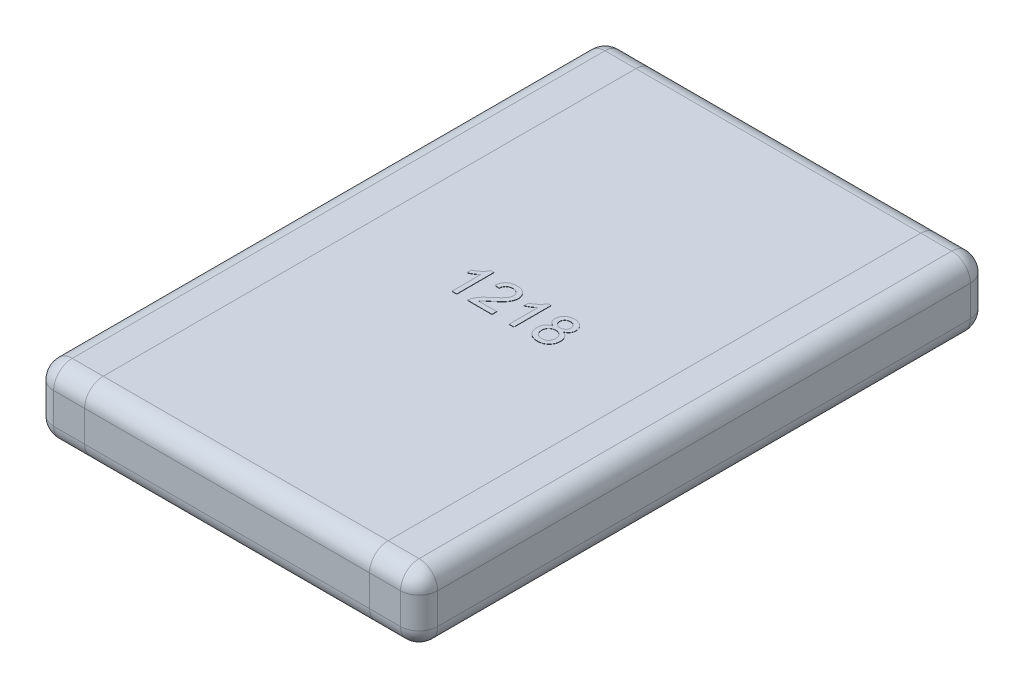
from build123d import *

# Parameters (mm, degrees)
SKETCH1_W      = 3.1
SKETCH1_H      = 4.6
EXTRUDE1_DEPTH = 0.55
FILLET1_R      = 0.15
EXTRUDE2_DEPTH = 0.002


with BuildPart() as part:
    # Sketch1 → Extrude1 (new body)
    with BuildSketch(Plane(origin=(0, 0, 0), x_dir=(1, 0, 0), z_dir=(0, 1, 0))):
        Rectangle(SKETCH1_W, SKETCH1_H)
    extrude(amount=EXTRUDE1_DEPTH)

    # Fillet1
    fillet1_edges = [part.edges().sort_by_distance(p)[0] for p in [
        (1.55, 0.55, 0),
        (0, 0.55, -2.3),
        (-1.55, 0.55, 0),
        (0, 0, -2.3),
        (1.55, 0, 0),
        (0, 0, 2.3),
        (-1.55, 0, 0),
        (0, 0.55, 2.3),
        (-1.55, 0.275, -2.3),
        (1.55, 0.275, -2.3),
        (1.55, 0.275, 2.3),
        (-1.55, 0.275, 2.3),
    ]]
    fillet(fillet1_edges, radius=FILLET1_R)

    # Sketch3 → Extrude2 (add)
    with BuildSketch(Plane(origin=(0, 0.55, 0), x_dir=(1, 0, 0), z_dir=(0, 1, 0))):
        with BuildLine():
            Line((-0.296153846, -0.15), (-0.334615385, -0.15))
            Line((-0.334615385, -0.15), (-0.334615385, 0.083774038))
            add(Edge.make_bspline(
                [(-0.334615385, 0.083774038), (-0.336830003, 0.081638311), (-0.341432846, 0.077199436), (-0.349213465, 0.070917319), (-0.35789763, 0.064550127), (-0.367372572, 0.05842736), (-0.377030672, 0.052663436), (-0.386363982, 0.047479672), (-0.39521668, 0.04309295), (-0.401047999, 0.040694273), (-0.403846154, 0.039543269)],
                knots=[0, 0, 0, 0, 9.226e-06, 1.9175e-05, 2.9969e-05, 4.1521e-05, 5.3002e-05, 6.3707e-05, 7.3544e-05, 8.2619e-05, 8.2619e-05, 8.2619e-05, 8.2619e-05], degree=3))
            Line((-0.403846154, 0.039543269), (-0.403846154, 0.075))
            add(Edge.make_bspline(
                [(-0.403846154, 0.075), (-0.399040034, 0.077475162), (-0.389567455, 0.082353558), (-0.37618475, 0.09077922), (-0.363690555, 0.099912985), (-0.352291699, 0.10975283), (-0.342073351, 0.119810917), (-0.333462201, 0.129959923), (-0.326256938, 0.139827828), (-0.322641922, 0.146709597), (-0.320913462, 0.15)],
                knots=[0, 0, 0, 0, 1.6212e-05, 3.1953e-05, 4.7386e-05, 6.26e-05, 7.7091e-05, 9.0349e-05, 0.000102505, 0.000113642, 0.000113642, 0.000113642, 0.000113642], degree=3))
            Line((-0.320913462, 0.15), (-0.296153846, 0.15))
            Line((-0.296153846, 0.15), (-0.296153846, -0.15))
        make_face()
        with BuildLine():
            Line((-0.011538462, -0.111538462), (-0.011538462, -0.15))
            Line((-0.011538462, -0.15), (-0.207692308, -0.15))
            add(Edge.make_bspline(
                [(-0.207692308, -0.15), (-0.207696323, -0.147714123), (-0.207704342, -0.14315003), (-0.206932024, -0.136400026), (-0.205722419, -0.129739566), (-0.204354719, -0.125468478), (-0.203665865, -0.123317308)],
                knots=[0, 0, 0, 0, 6.852e-06, 1.3681e-05, 2.0352e-05, 2.7121e-05, 2.7121e-05, 2.7121e-05, 2.7121e-05], degree=3))
            add(Edge.make_bspline(
                [(-0.203665865, -0.123317308), (-0.202393093, -0.119802551), (-0.199801518, -0.112645929), (-0.19455096, -0.102319922), (-0.188375063, -0.092056365), (-0.182361958, -0.08370038), (-0.176855252, -0.077024532), (-0.172237162, -0.071801454), (-0.167119471, -0.066455018), (-0.161506278, -0.060986201), (-0.155451607, -0.055359583), (-0.148947197, -0.049556401), (-0.141916239, -0.043684801), (-0.137007895, -0.039792861), (-0.134495192, -0.037800481)],
                knots=[0, 0, 0, 0, 1.1205e-05, 2.2816e-05, 3.4678e-05, 4.712e-05, 5.3653e-05, 6.0635e-05, 6.8031e-05, 7.5851e-05, 8.4142e-05, 9.2826e-05, 0.000101998, 0.000111618, 0.000111618, 0.000111618, 0.000111618], degree=3))
            add(Edge.make_bspline(
                [(-0.134495192, -0.037800481), (-0.130635061, -0.034551471), (-0.123202132, -0.028295295), (-0.112705672, -0.019011711), (-0.103118865, -0.010391377), (-0.094594368, -0.002283205), (-0.087062462, 0.005234162), (-0.080505461, 0.012143692), (-0.074866946, 0.018423822), (-0.070215752, 0.024301865), (-0.066291398, 0.029852373), (-0.062965854, 0.035266551), (-0.060194454, 0.040638972), (-0.057886249, 0.045952637), (-0.056060655, 0.05123027), (-0.054816253, 0.056487246), (-0.053972343, 0.061671403), (-0.053887909, 0.065120999), (-0.053846154, 0.066826923)],
                knots=[0, 0, 0, 0, 1.5136e-05, 2.9145e-05, 4.2036e-05, 5.3811e-05, 6.4435e-05, 7.3957e-05, 8.2386e-05, 8.9745e-05, 9.643e-05, 0.000102769, 0.00010879, 0.00011455, 0.000120137, 0.000125516, 0.000130743, 0.000135857, 0.000135857, 0.000135857, 0.000135857], degree=3))
            add(Edge.make_bspline(
                [(-0.053846154, 0.066826923), (-0.053887914, 0.068512943), (-0.053969845, 0.071820821), (-0.054747201, 0.076661881), (-0.055829343, 0.081323937), (-0.057578837, 0.085723063), (-0.059661262, 0.089989532), (-0.062332474, 0.093988532), (-0.065422517, 0.097819726), (-0.068960356, 0.101382104), (-0.072824504, 0.104724183), (-0.077142138, 0.107502263), (-0.081629679, 0.110003363), (-0.086441941, 0.11201439), (-0.091571106, 0.113491124), (-0.096979835, 0.114562852), (-0.10266727, 0.115242385), (-0.106548545, 0.115336486), (-0.108533654, 0.115384615)],
                knots=[0, 0, 0, 0, 5.054e-06, 9.915e-06, 1.4681e-05, 1.938e-05, 2.4083e-05, 2.89e-05, 3.3772e-05, 3.8829e-05, 4.3946e-05, 4.9063e-05, 5.4199e-05, 5.9345e-05, 6.4669e-05, 7.0185e-05, 7.5872e-05, 8.1827e-05, 8.1827e-05, 8.1827e-05, 8.1827e-05], degree=3))
            add(Edge.make_bspline(
                [(-0.108533654, 0.115384615), (-0.110618956, 0.115336725), (-0.114700045, 0.115242999), (-0.120665504, 0.114560756), (-0.126328674, 0.113518381), (-0.131676037, 0.111924678), (-0.136701084, 0.109917004), (-0.141383351, 0.107389877), (-0.145797819, 0.104537208), (-0.149805459, 0.101159863), (-0.153429516, 0.097415076), (-0.156646835, 0.093338135), (-0.159282944, 0.088850365), (-0.161459952, 0.084050442), (-0.163210448, 0.078923275), (-0.164481249, 0.07342967), (-0.165174098, 0.067585487), (-0.165313425, 0.063583392), (-0.165384615, 0.061538462)],
                knots=[0, 0, 0, 0, 6.255e-06, 1.2241e-05, 1.7992e-05, 2.3507e-05, 2.8953e-05, 3.4195e-05, 3.9446e-05, 4.4693e-05, 4.9878e-05, 5.506e-05, 6.0233e-05, 6.5451e-05, 7.0848e-05, 7.6461e-05, 8.2334e-05, 8.8471e-05, 8.8471e-05, 8.8471e-05, 8.8471e-05], degree=3))
            Line((-0.165384615, 0.061538462), (-0.203846154, 0.065384615))
            add(Edge.make_bspline(
                [(-0.203846154, 0.065384615), (-0.203452638, 0.068736632), (-0.202687086, 0.075257693), (-0.200780201, 0.084702351), (-0.198103106, 0.09348859), (-0.194899737, 0.101738909), (-0.190884012, 0.109312863), (-0.18634458, 0.11636711), (-0.18099053, 0.122677919), (-0.175075725, 0.128444216), (-0.168535362, 0.133525841), (-0.161430878, 0.137965346), (-0.153765522, 0.141678718), (-0.145581988, 0.144753235), (-0.136861488, 0.147085948), (-0.12761636, 0.148758724), (-0.117831734, 0.149789842), (-0.111120341, 0.149928948), (-0.107692308, 0.15)],
                knots=[0, 0, 0, 0, 1.0123e-05, 1.9693e-05, 2.8857e-05, 3.7651e-05, 4.6199e-05, 5.4533e-05, 6.2766e-05, 7.0968e-05, 7.9275e-05, 8.7563e-05, 9.6056e-05, 0.000104785, 0.00011375, 0.000123098, 0.000132946, 0.000143229, 0.000143229, 0.000143229, 0.000143229], degree=3))
            add(Edge.make_bspline(
                [(-0.107692308, 0.15), (-0.104223243, 0.149940596), (-0.097465484, 0.149824877), (-0.087618344, 0.14864084), (-0.078327294, 0.146796713), (-0.069558275, 0.144226564), (-0.061363096, 0.140856333), (-0.053735451, 0.136738671), (-0.046640172, 0.131913745), (-0.040195807, 0.126323636), (-0.034384754, 0.120221095), (-0.029292223, 0.113708369), (-0.025034622, 0.106813279), (-0.021409539, 0.09962981), (-0.018720681, 0.092006182), (-0.016829827, 0.084046037), (-0.015544936, 0.075742575), (-0.015438766, 0.070077103), (-0.015384615, 0.0671875)],
                knots=[0, 0, 0, 0, 1.0403e-05, 2.0265e-05, 2.9705e-05, 3.8794e-05, 4.7633e-05, 5.6238e-05, 6.4755e-05, 7.3321e-05, 8.178e-05, 9.0002e-05, 9.8073e-05, 0.000106055, 0.000114096, 0.000122258, 0.000130579, 0.00013924, 0.00013924, 0.00013924, 0.00013924], degree=3))
            add(Edge.make_bspline(
                [(-0.015384615, 0.0671875), (-0.015467303, 0.06421876), (-0.01563286, 0.058274728), (-0.016925056, 0.049390154), (-0.019136019, 0.040601997), (-0.022067165, 0.0318033), (-0.026071721, 0.022959142), (-0.031130797, 0.013947517), (-0.037407134, 0.004735138), (-0.04344321, -0.003096409), (-0.049061817, -0.009661219), (-0.054042181, -0.015064442), (-0.059804175, -0.020805005), (-0.066131643, -0.027081717), (-0.073282651, -0.033671804), (-0.081051734, -0.040772611), (-0.089608959, -0.048197271), (-0.095549342, -0.053269443), (-0.098617788, -0.055889423)],
                knots=[0, 0, 0, 0, 8.904e-06, 1.7828e-05, 2.6865e-05, 3.6063e-05, 4.5612e-05, 5.5944e-05, 6.7028e-05, 7.9024e-05, 8.5588e-05, 9.2946e-05, 0.000101063, 0.000109987, 0.000119681, 0.000130232, 0.000141562, 0.000153666, 0.000153666, 0.000153666, 0.000153666], degree=3))
            add(Edge.make_bspline(
                [(-0.098617788, -0.055889423), (-0.101245449, -0.058028619), (-0.106255994, -0.062107737), (-0.113384465, -0.068021343), (-0.119769407, -0.07344396), (-0.12556013, -0.078198712), (-0.130545741, -0.08251558), (-0.13490185, -0.086205504), (-0.138470198, -0.089454013), (-0.14390416, -0.094388563), (-0.150786737, -0.101422266), (-0.155858114, -0.108256719), (-0.158293269, -0.111538462)],
                knots=[0, 0, 0, 0, 1.0165e-05, 1.9383e-05, 2.7786e-05, 3.5295e-05, 4.1859e-05, 4.7569e-05, 5.242e-05, 5.6334e-05, 6.9594e-05, 8.1844e-05, 8.1844e-05, 8.1844e-05, 8.1844e-05], degree=3))
            Line((-0.158293269, -0.111538462), (-0.011538462, -0.111538462))
        make_face()
        with BuildLine():
            Line((0.165384615, -0.15), (0.126923077, -0.15))
            Line((0.126923077, -0.15), (0.126923077, 0.083774038))
            add(Edge.make_bspline(
                [(0.126923077, 0.083774038), (0.124708458, 0.081638311), (0.120105616, 0.077199436), (0.112324997, 0.070917319), (0.103640832, 0.064550127), (0.09416589, 0.05842736), (0.08450779, 0.052663436), (0.075174479, 0.047479672), (0.066321782, 0.04309295), (0.060490463, 0.040694273), (0.057692308, 0.039543269)],
                knots=[0, 0, 0, 0, 9.226e-06, 1.9175e-05, 2.9969e-05, 4.1521e-05, 5.3002e-05, 6.3707e-05, 7.3544e-05, 8.2619e-05, 8.2619e-05, 8.2619e-05, 8.2619e-05], degree=3))
            Line((0.057692308, 0.039543269), (0.057692308, 0.075))
            add(Edge.make_bspline(
                [(0.057692308, 0.075), (0.062498428, 0.077475162), (0.071971006, 0.082353558), (0.085353711, 0.09077922), (0.097847906, 0.099912985), (0.109246762, 0.10975283), (0.11946511, 0.119810917), (0.128076261, 0.129959923), (0.135281523, 0.139827828), (0.13889654, 0.146709597), (0.140625, 0.15)],
                knots=[0, 0, 0, 0, 1.6212e-05, 3.1953e-05, 4.7386e-05, 6.26e-05, 7.7091e-05, 9.0349e-05, 0.000102505, 0.000113642, 0.000113642, 0.000113642, 0.000113642], degree=3))
            Line((0.140625, 0.15), (0.165384615, 0.15))
            Line((0.165384615, 0.15), (0.165384615, -0.15))
        make_face()
        with BuildLine():
            add(Edge.make_bspline(
                [(0.318509615, 0.014543269), (0.314860295, 0.015970904), (0.307863336, 0.018708154), (0.298426244, 0.024186161), (0.290439253, 0.030487887), (0.284000435, 0.037765293), (0.279092884, 0.045867936), (0.275559254, 0.054692508), (0.273489545, 0.06428817), (0.273217147, 0.070923324), (0.273076923, 0.074338942)],
                knots=[0, 0, 0, 0, 1.1742e-05, 2.2513e-05, 3.2603e-05, 4.214e-05, 5.1498e-05, 6.0884e-05, 7.0537e-05, 8.0779e-05, 8.0779e-05, 8.0779e-05, 8.0779e-05], degree=3))
            add(Edge.make_bspline(
                [(0.273076923, 0.074338942), (0.27314292, 0.07696711), (0.273272474, 0.082126286), (0.274391848, 0.089696504), (0.276184688, 0.096950666), (0.278729147, 0.103868299), (0.281916936, 0.11050634), (0.28593939, 0.11674318), (0.29056295, 0.122755082), (0.295979231, 0.128299027), (0.301947879, 0.133376745), (0.308412856, 0.137895415), (0.315423633, 0.141590589), (0.322863319, 0.144680065), (0.330768701, 0.147098798), (0.339167624, 0.148746091), (0.348030483, 0.149793891), (0.354103523, 0.149930227), (0.357211538, 0.15)],
                knots=[0, 0, 0, 0, 7.881e-06, 1.547e-05, 2.2904e-05, 3.0261e-05, 3.7545e-05, 4.4948e-05, 5.2485e-05, 6.0262e-05, 6.8149e-05, 7.5968e-05, 8.3872e-05, 9.1874e-05, 0.000100106, 0.000108627, 0.00011752, 0.000126842, 0.000126842, 0.000126842, 0.000126842], degree=3))
            add(Edge.make_bspline(
                [(0.357211538, 0.15), (0.360339358, 0.149929518), (0.366431998, 0.149792228), (0.375341942, 0.148758507), (0.383793869, 0.147025925), (0.391782801, 0.144567827), (0.399321334, 0.141425001), (0.406359932, 0.137562056), (0.412971053, 0.133042703), (0.418985719, 0.127813048), (0.424458348, 0.122135343), (0.429199864, 0.1160526), (0.433266512, 0.109706754), (0.436626985, 0.103059254), (0.439113075, 0.096034402), (0.441008035, 0.088764549), (0.442107199, 0.081163316), (0.442240027, 0.076005089), (0.442307692, 0.073377404)],
                knots=[0, 0, 0, 0, 9.382e-06, 1.8275e-05, 2.6867e-05, 3.5231e-05, 4.3312e-05, 5.1326e-05, 5.9277e-05, 6.7288e-05, 7.5194e-05, 8.29e-05, 9.0385e-05, 9.7776e-05, 0.00010519, 0.000112697, 0.000120286, 0.000128167, 0.000128167, 0.000128167, 0.000128167], degree=3))
            add(Edge.make_bspline(
                [(0.442307692, 0.073377404), (0.442197773, 0.070079507), (0.441982241, 0.063612951), (0.439785876, 0.054291357), (0.436362653, 0.045589182), (0.431415063, 0.037672273), (0.425149124, 0.030458869), (0.417373593, 0.024188177), (0.408206557, 0.018718731), (0.401386261, 0.015972556), (0.397836538, 0.014543269)],
                knots=[0, 0, 0, 0, 9.878e-06, 1.9369e-05, 2.8564e-05, 3.782e-05, 4.7233e-05, 5.7098e-05, 6.7662e-05, 7.9128e-05, 7.9128e-05, 7.9128e-05, 7.9128e-05], degree=3))
            add(Edge.make_bspline(
                [(0.397836538, 0.014543269), (0.400076183, 0.013783016), (0.404464914, 0.01229325), (0.41066927, 0.009396685), (0.416510485, 0.006273501), (0.422021497, 0.002892652), (0.426998883, -0.000997287), (0.431608702, -0.00516632), (0.435831572, -0.009673198), (0.439609814, -0.014556251), (0.442983014, -0.019712993), (0.445870741, -0.025155995), (0.448323232, -0.030807785), (0.450419215, -0.036694571), (0.451950165, -0.042857817), (0.453021351, -0.049269202), (0.453700988, -0.055894934), (0.453797262, -0.060394987), (0.453846154, -0.062680288)],
                knots=[0, 0, 0, 0, 7.091e-06, 1.3894e-05, 2.0509e-05, 2.6962e-05, 3.326e-05, 3.9429e-05, 4.5594e-05, 5.1761e-05, 5.7929e-05, 6.4058e-05, 7.0221e-05, 7.6399e-05, 8.2783e-05, 8.9244e-05, 9.5888e-05, 0.000102743, 0.000102743, 0.000102743, 0.000102743], degree=3))
            add(Edge.make_bspline(
                [(0.453846154, -0.062680288), (0.45376972, -0.065830053), (0.453619139, -0.07203533), (0.452296087, -0.081143948), (0.450294251, -0.089894018), (0.447375342, -0.098248578), (0.443647171, -0.106213532), (0.439035378, -0.113777315), (0.433585276, -0.120932146), (0.427457634, -0.127700265), (0.420606933, -0.133818351), (0.413195743, -0.139209736), (0.405196258, -0.143725707), (0.396705537, -0.147464915), (0.387682925, -0.150362788), (0.378140019, -0.152391913), (0.368079995, -0.153600168), (0.361201262, -0.15376306), (0.357692308, -0.153846154)],
                knots=[0, 0, 0, 0, 9.444e-06, 1.8606e-05, 2.7557e-05, 3.6337e-05, 4.5101e-05, 5.3893e-05, 6.2859e-05, 7.2048e-05, 8.1241e-05, 9.0365e-05, 9.9489e-05, 0.000108745, 0.000118153, 0.000127865, 0.000137973, 0.000148498, 0.000148498, 0.000148498, 0.000148498], degree=3))
            add(Edge.make_bspline(
                [(0.357692308, -0.153846154), (0.354183704, -0.153761269), (0.347305659, -0.153594866), (0.337236444, -0.152411313), (0.327707192, -0.150290202), (0.318696311, -0.147389384), (0.310154921, -0.143751415), (0.30220916, -0.139133687), (0.294749561, -0.133749133), (0.287894096, -0.127593205), (0.281715554, -0.120825808), (0.276337297, -0.113565311), (0.271752882, -0.105923451), (0.267980008, -0.097857148), (0.265104217, -0.089366329), (0.263085953, -0.080482873), (0.261760507, -0.071213566), (0.26161352, -0.064888503), (0.261538462, -0.061658654)],
                knots=[0, 0, 0, 0, 1.0525e-05, 2.0633e-05, 3.0358e-05, 3.9766e-05, 4.8998e-05, 5.8152e-05, 6.7276e-05, 7.6554e-05, 8.5742e-05, 9.4721e-05, 0.000103615, 0.000112434, 0.000121385, 0.000130452, 0.000139733, 0.000149418, 0.000149418, 0.000149418, 0.000149418], degree=3))
            add(Edge.make_bspline(
                [(0.261538462, -0.061658654), (0.261590633, -0.05925379), (0.261693001, -0.054535032), (0.262318335, -0.047613898), (0.263564614, -0.04101733), (0.265169901, -0.034706454), (0.267208113, -0.028665483), (0.269722636, -0.022941855), (0.2727734, -0.017549405), (0.276239267, -0.012453043), (0.280163974, -0.007688549), (0.284483909, -0.003297645), (0.289214766, 0.000669723), (0.294250232, 0.004329433), (0.299801377, 0.007422605), (0.305661755, 0.010261167), (0.311932122, 0.012681934), (0.31629516, 0.01391661), (0.318509615, 0.014543269)],
                knots=[0, 0, 0, 0, 7.216e-06, 1.4158e-05, 2.0818e-05, 2.7333e-05, 3.3681e-05, 3.9923e-05, 4.6058e-05, 5.2242e-05, 5.839e-05, 6.4552e-05, 7.0692e-05, 7.6896e-05, 8.3194e-05, 8.9726e-05, 9.6422e-05, 0.000103324, 0.000103324, 0.000103324, 0.000103324], degree=3))
        make_face()
        with BuildLine():
            add(Edge.make_bspline(
                [(0.311538462, 0.074158654), (0.311652615, 0.071096846), (0.31187321, 0.065180074), (0.314272205, 0.056775734), (0.318023536, 0.049226279), (0.322421313, 0.043751589), (0.326637678, 0.0400214), (0.330156814, 0.037530885), (0.33400255, 0.035416488), (0.338202746, 0.033773046), (0.342655672, 0.032317058), (0.347514904, 0.031503267), (0.352666229, 0.030841703), (0.35622746, 0.03079379), (0.358052885, 0.030769231)],
                knots=[0, 0, 0, 0, 9.163e-06, 1.7707e-05, 2.5985e-05, 3.4319e-05, 3.8576e-05, 4.2845e-05, 4.7228e-05, 5.1704e-05, 5.6361e-05, 6.1252e-05, 6.6455e-05, 7.1927e-05, 7.1927e-05, 7.1927e-05, 7.1927e-05], degree=3))
            add(Edge.make_bspline(
                [(0.358052885, 0.030769231), (0.359838014, 0.030794697), (0.36331892, 0.030844356), (0.368354225, 0.031492433), (0.37311257, 0.032358), (0.377523642, 0.033669634), (0.381638366, 0.035375141), (0.385389817, 0.037477611), (0.388890258, 0.039893951), (0.392982761, 0.043652639), (0.397374469, 0.048935583), (0.401138372, 0.056147793), (0.403483876, 0.064038379), (0.403723275, 0.069534632), (0.403846154, 0.072355769)],
                knots=[0, 0, 0, 0, 5.352e-06, 1.0435e-05, 1.5209e-05, 1.9848e-05, 2.4212e-05, 2.8543e-05, 3.2728e-05, 3.694e-05, 4.5181e-05, 5.3192e-05, 6.1199e-05, 6.9644e-05, 6.9644e-05, 6.9644e-05, 6.9644e-05], degree=3))
            add(Edge.make_bspline(
                [(0.403846154, 0.072355769), (0.403698102, 0.075275526), (0.403408402, 0.080988733), (0.401068627, 0.089190299), (0.397129411, 0.096618469), (0.392629404, 0.102043156), (0.388464504, 0.105973023), (0.384901221, 0.108474646), (0.381070677, 0.110603749), (0.376958295, 0.112342448), (0.372558128, 0.113744726), (0.367858256, 0.114664689), (0.362878428, 0.115309891), (0.359457389, 0.115359183), (0.357692308, 0.115384615)],
                knots=[0, 0, 0, 0, 8.749e-06, 1.7119e-05, 2.5345e-05, 3.3802e-05, 3.814e-05, 4.2492e-05, 4.6823e-05, 5.1266e-05, 5.5866e-05, 6.0651e-05, 6.5615e-05, 7.0907e-05, 7.0907e-05, 7.0907e-05, 7.0907e-05], degree=3))
            add(Edge.make_bspline(
                [(0.357692308, 0.115384615), (0.35592703, 0.115360006), (0.352485708, 0.11531203), (0.347473407, 0.114647467), (0.342728995, 0.113812789), (0.33829624, 0.112473285), (0.334193568, 0.110722865), (0.330378126, 0.108592567), (0.326821594, 0.106154844), (0.322627433, 0.102400216), (0.318234741, 0.097117152), (0.314364903, 0.09002013), (0.311973218, 0.08228198), (0.311685175, 0.076899968), (0.311538462, 0.074158654)],
                knots=[0, 0, 0, 0, 5.292e-06, 1.0316e-05, 1.5148e-05, 1.973e-05, 2.4173e-05, 2.8504e-05, 3.2821e-05, 3.7078e-05, 4.5358e-05, 5.3291e-05, 6.12e-05, 6.941e-05, 6.941e-05, 6.941e-05, 6.941e-05], degree=3))
        make_face(mode=Mode.SUBTRACT)
        with BuildLine():
            add(Edge.make_bspline(
                [(0.3, -0.0609375), (0.300066509, -0.063405403), (0.300199701, -0.06834771), (0.301368087, -0.075688083), (0.303350594, -0.082891764), (0.305891523, -0.089965559), (0.309475662, -0.096623957), (0.314228632, -0.102567066), (0.32019272, -0.107563675), (0.327004035, -0.111784999), (0.33443693, -0.115107544), (0.342182224, -0.117426794), (0.350040015, -0.118959238), (0.355341561, -0.119140248), (0.357992788, -0.119230769)],
                knots=[0, 0, 0, 0, 7.401e-06, 1.4821e-05, 2.2226e-05, 2.9795e-05, 3.7325e-05, 4.4805e-05, 5.2477e-05, 6.0548e-05, 6.8779e-05, 7.6821e-05, 8.4765e-05, 9.2713e-05, 9.2713e-05, 9.2713e-05, 9.2713e-05], degree=3))
            add(Edge.make_bspline(
                [(0.357992788, -0.119230769), (0.360179012, -0.119193736), (0.36442622, -0.119121792), (0.370617319, -0.11829967), (0.376450735, -0.117052243), (0.381953192, -0.115341816), (0.387043701, -0.113001839), (0.391805158, -0.110266914), (0.396188859, -0.106961547), (0.400193564, -0.10318929), (0.403778485, -0.099016466), (0.406849423, -0.094514901), (0.409528239, -0.08981119), (0.411715369, -0.08480382), (0.413297017, -0.079482465), (0.414517482, -0.073943134), (0.415253752, -0.068128692), (0.415340362, -0.064164781), (0.415384615, -0.062139423)],
                knots=[0, 0, 0, 0, 6.555e-06, 1.2734e-05, 1.8699e-05, 2.4438e-05, 2.9979e-05, 3.5473e-05, 4.0881e-05, 4.6408e-05, 5.1949e-05, 5.735e-05, 6.2732e-05, 6.8169e-05, 7.37e-05, 7.9358e-05, 8.5173e-05, 9.1247e-05, 9.1247e-05, 9.1247e-05, 9.1247e-05], degree=3))
            add(Edge.make_bspline(
                [(0.415384615, -0.062139423), (0.415338953, -0.06007431), (0.415249553, -0.056031148), (0.414531993, -0.050089091), (0.413243093, -0.044452304), (0.411585561, -0.039035631), (0.409339132, -0.033933308), (0.406642609, -0.029072172), (0.403340463, -0.024580352), (0.399719396, -0.020305352), (0.395621562, -0.016435488), (0.39109627, -0.013098358), (0.386286937, -0.010151107), (0.381048077, -0.007890317), (0.375495109, -0.006079372), (0.369601652, -0.004763512), (0.363343676, -0.003959162), (0.35905699, -0.003884551), (0.356850962, -0.003846154)],
                knots=[0, 0, 0, 0, 6.195e-06, 1.2128e-05, 1.7916e-05, 2.3523e-05, 2.9094e-05, 3.4611e-05, 4.0164e-05, 4.579e-05, 5.1402e-05, 5.7027e-05, 6.2633e-05, 6.8284e-05, 7.4099e-05, 8.0135e-05, 8.6374e-05, 9.2989e-05, 9.2989e-05, 9.2989e-05, 9.2989e-05], degree=3))
            add(Edge.make_bspline(
                [(0.356850962, -0.003846154), (0.354704839, -0.003884933), (0.350497771, -0.003960952), (0.344386064, -0.004769858), (0.338600156, -0.00601207), (0.33319095, -0.007830212), (0.328090815, -0.010102166), (0.323393031, -0.012958985), (0.31901379, -0.016274938), (0.315086861, -0.020129101), (0.311543754, -0.02431577), (0.308480358, -0.028803867), (0.305774159, -0.033489281), (0.303720481, -0.038525757), (0.301982227, -0.043750476), (0.300895543, -0.049264843), (0.300123046, -0.055006205), (0.300041615, -0.058931505), (0.3, -0.0609375)],
                knots=[0, 0, 0, 0, 6.435e-06, 1.2614e-05, 1.8461e-05, 2.4162e-05, 2.9703e-05, 3.5176e-05, 4.0621e-05, 4.6146e-05, 5.1647e-05, 5.7048e-05, 6.243e-05, 6.7843e-05, 7.3336e-05, 7.8923e-05, 8.4677e-05, 9.0691e-05, 9.0691e-05, 9.0691e-05, 9.0691e-05], degree=3))
        make_face(mode=Mode.SUBTRACT)
    extrude(amount=EXTRUDE2_DEPTH)


solid = part.part
